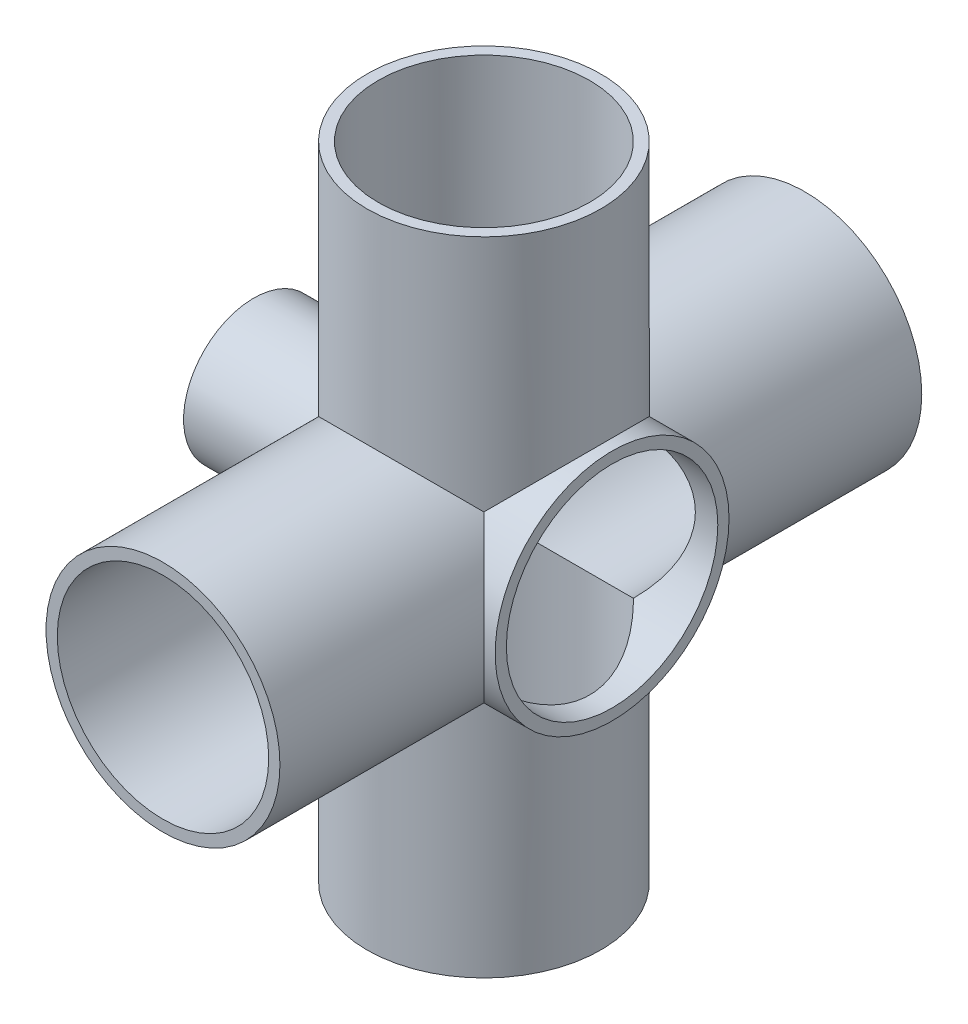
from build123d import *

# Parameters (mm, degrees)
SKETCH1_R               = 31.75
EXTRUDE3_DEPTH          = 87.122
EXTRUDE3_DEPTH_BACK     = 87.122
SKETCH4_R               = 31.75
EXTRUDE4_DEPTH          = 87.122
EXTRUDE4_DEPTH_BACK     = 87.122
SKETCH6_R               = 31.75
EXTRUDE5_DEPTH          = 34.798
SKETCH7_R               = 19.05
EXTRUDE6_DEPTH          = 62.484
SKETCH9_R               = 28.702
CUT_EXTRUDE1_DEPTH      = 88.1220001
CUT_EXTRUDE1_DEPTH_BACK = 88.1220001
SKETCH10_R              = 28.702
CUT_EXTRUDE2_DEPTH      = 88.1220001
CUT_EXTRUDE2_DEPTH_BACK = 88.1220001
SKETCH11_R              = 28.702
CUT_EXTRUDE3_DEPTH      = 35.798
SKETCH12_R              = 17.399
CUT_EXTRUDE4_DEPTH      = 63.4840001


with BuildPart() as part:
    # Sketch1 → Extrude3 (new body, two sides)
    with BuildSketch(Plane(origin=(0, 0, 0), x_dir=(1, 0, 0), z_dir=(0, 1, 0))) as extrude3_sk:
        Circle(SKETCH1_R)
    extrude(amount=EXTRUDE3_DEPTH)
    extrude(extrude3_sk.sketch, amount=-EXTRUDE3_DEPTH_BACK)

    # Sketch4 → Extrude4 (add, two sides)
    with BuildSketch(Plane.XY) as extrude4_sk:
        Circle(SKETCH4_R)
    extrude(amount=EXTRUDE4_DEPTH)
    extrude(extrude4_sk.sketch, amount=-EXTRUDE4_DEPTH_BACK)

    # Sketch6 → Extrude5 (add)
    with BuildSketch(Plane(origin=(0, 0, 0), x_dir=(0, 0, -1), z_dir=(1, 0, 0))):
        Circle(SKETCH6_R)
    extrude(amount=EXTRUDE5_DEPTH)

    # Sketch7 → Extrude6 (add)
    with BuildSketch(Plane(origin=(0, 0, 0), x_dir=(0, 0, -1), z_dir=(1, 0, 0))):
        Circle(SKETCH7_R)
    extrude(amount=-EXTRUDE6_DEPTH)

    # Sketch9 → Cut-Extrude1 (cut, two sides)
    with BuildSketch(Plane(origin=(0, 0, 0), x_dir=(1, 0, 0), z_dir=(0, 1, 0))) as cut_extrude1_sk:
        Circle(SKETCH9_R)
    extrude(amount=CUT_EXTRUDE1_DEPTH, mode=Mode.SUBTRACT)
    extrude(cut_extrude1_sk.sketch, amount=-CUT_EXTRUDE1_DEPTH_BACK, mode=Mode.SUBTRACT)

    # Sketch10 → Cut-Extrude2 (cut, two sides)
    with BuildSketch(Plane.XY) as cut_extrude2_sk:
        Circle(SKETCH10_R)
    extrude(amount=CUT_EXTRUDE2_DEPTH, mode=Mode.SUBTRACT)
    extrude(cut_extrude2_sk.sketch, amount=-CUT_EXTRUDE2_DEPTH_BACK, mode=Mode.SUBTRACT)

    # Sketch11 → Cut-Extrude3 (cut, through all)
    with BuildSketch(Plane(origin=(0, 0, 0), x_dir=(0, 0, -1), z_dir=(1, 0, 0))):
        Circle(SKETCH11_R)
    extrude(amount=CUT_EXTRUDE3_DEPTH, mode=Mode.SUBTRACT)

    # Sketch12 → Cut-Extrude4 (cut, through all)
    with BuildSketch(Plane(origin=(0, 0, 0), x_dir=(0, 0, -1), z_dir=(1, 0, 0))):
        Circle(SKETCH12_R)
    extrude(amount=-CUT_EXTRUDE4_DEPTH, mode=Mode.SUBTRACT)


solid = part.part
